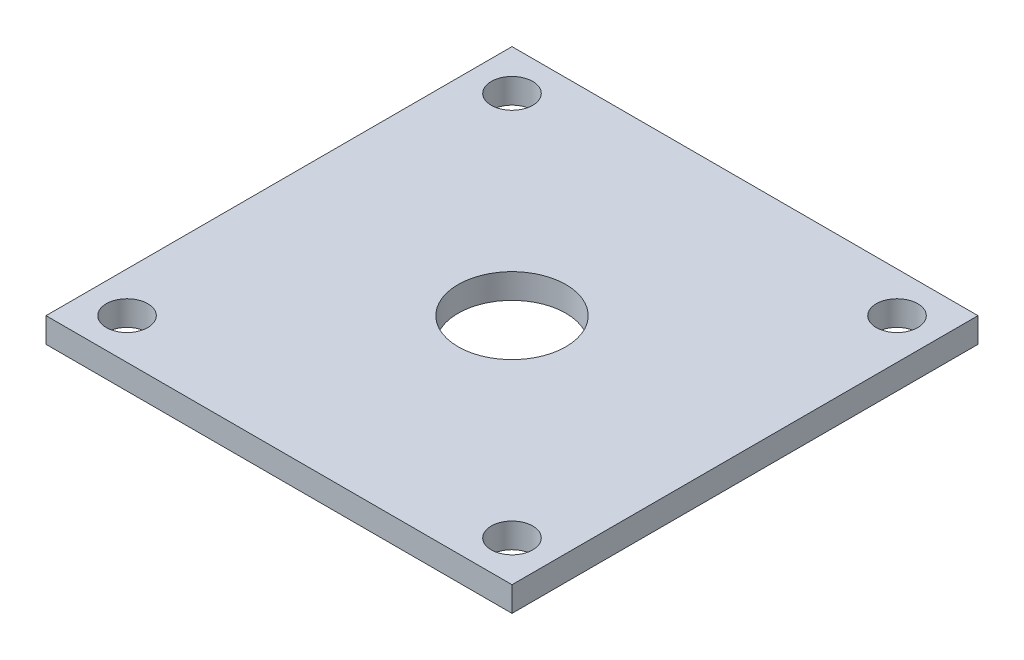
from build123d import *

# Parameters (mm, degrees)
SKETCH3_W            = 71.374
SKETCH3_H            = 71.374
BOSS_EXTRUDE1_DEPTH  = 88.9508
SHELL1_T             = 5.08
CUT_EXTRUDE1_REACH   = 7.08
SKETCH4_R            = 8.255
SKETCH15_OUTSIDE_W   = 100.282
SKETCH15_OUTSIDE_H   = 117.859
SKETCH15_OUTSIDE_W_2 = 71.374
SKETCH15_OUTSIDE_H_2 = 3.81
CUT_EXTRUDE14_DEPTH  = 72.374
CUT_EXTRUDE15_START  = 88.9508
SKETCH20_R           = 3.175
CUT_EXTRUDE15_DEPTH  = 89.9508
SKETCH6_W            = 71.374
SKETCH6_H            = 5.08
CUT_EXTRUDE3_DEPTH   = 5.08


with BuildPart() as part:
    # Sketch3 → Boss-Extrude1 (new body)
    with BuildSketch(Plane(origin=(0, 0, 0), x_dir=(1, 0, 0), z_dir=(0, 1, 0))):
        Rectangle(SKETCH3_W, SKETCH3_H)
    extrude(amount=BOSS_EXTRUDE1_DEPTH)

    # Shell1 (no face opened: a closed hollow body)
    add(offset(amount=-SHELL1_T, mode=Mode.PRIVATE), mode=Mode.SUBTRACT)

    # Sketch4 → Cut-Extrude1 (cut, up to next)
    with BuildSketch(Plane(origin=(0, 83.8708, 0), x_dir=(-1, 0, 0), z_dir=(0, -1, 0)), mode=Mode.PRIVATE) as cut_extrude1_sk1:
        Circle(SKETCH4_R)
    cut_extrude1_tool1 = extrude(cut_extrude1_sk1.sketch, amount=-CUT_EXTRUDE1_REACH, mode=Mode.PRIVATE) & part.part
    add(cut_extrude1_tool1.solids().sort_by_distance((0, 83.8708, 0))[0], mode=Mode.SUBTRACT)

    # Sketch15 outside → Cut-Extrude14 (cut, through all)
    with BuildSketch(Plane.XY.offset(35.687)):
        with Locations((0, 44.4755)):
            Rectangle(SKETCH15_OUTSIDE_W, SKETCH15_OUTSIDE_H)
        with Locations((0, 87.0458)):
            Rectangle(SKETCH15_OUTSIDE_W_2, SKETCH15_OUTSIDE_H_2, mode=Mode.SUBTRACT)
    extrude(amount=-CUT_EXTRUDE14_DEPTH, mode=Mode.SUBTRACT)

    # Sketch20 → Cut-Extrude15 (cut, through all)
    with BuildSketch(Plane(origin=(0, 0, 0), x_dir=(1, 0, 0), z_dir=(0, 1, 0)).offset(CUT_EXTRUDE15_START)):
        with Locations((-29.482513587, 29.482513587)):
            Circle(SKETCH20_R)
        with Locations((29.484795022, -29.484795022)):
            Circle(SKETCH20_R)
        with Locations((-29.48121109, -29.48121109)):
            Circle(SKETCH20_R)
        with Locations((29.484795022, 29.484795022)):
            Circle(SKETCH20_R)
    extrude(amount=-CUT_EXTRUDE15_DEPTH, mode=Mode.SUBTRACT)

    # Sketch6 → Cut-Extrude3 (cut)
    with BuildSketch(Plane(origin=(0, 0, 30.607), x_dir=(-1, 0, 0), z_dir=(0, 0, -1))):
        with Locations((0, 2.54)):
            Rectangle(SKETCH6_W, SKETCH6_H)
    extrude(amount=-CUT_EXTRUDE3_DEPTH, mode=Mode.SUBTRACT)


solid = part.part
